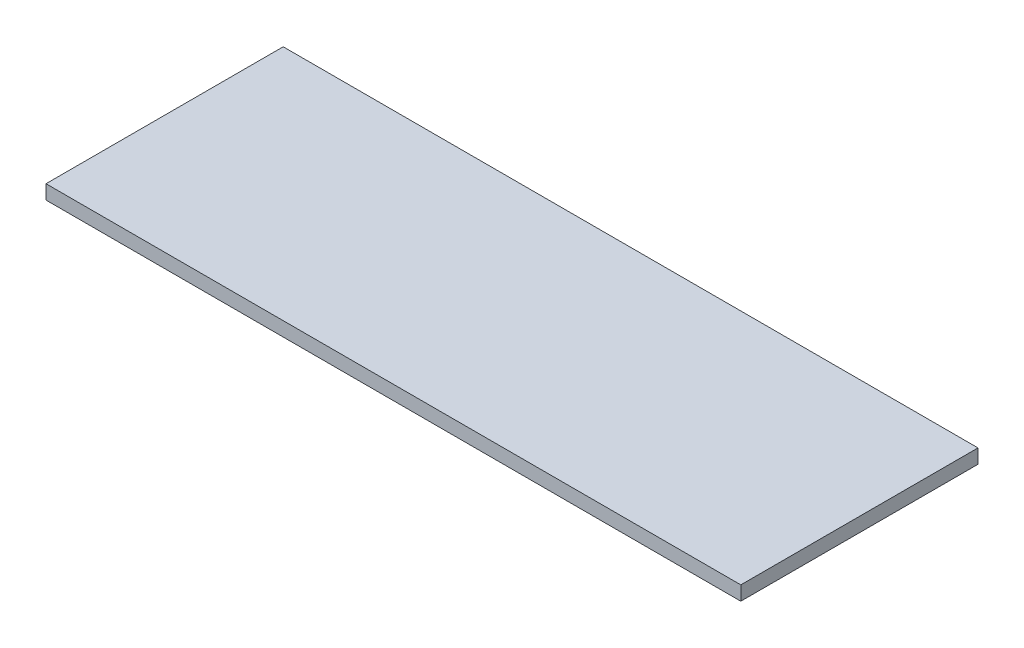
from build123d import *

# Parameters (mm, degrees)
SKETCH1_W           = 1860
SKETCH1_H           = 635
BOSS_EXTRUDE1_DEPTH = 38


with BuildPart() as part:
    # Sketch1 → Boss-Extrude1 (new body)
    with BuildSketch(Plane(origin=(0, 0, 0), x_dir=(1, 0, 0), z_dir=(0, 1, 0))):
        Rectangle(SKETCH1_W, SKETCH1_H)
    extrude(amount=BOSS_EXTRUDE1_DEPTH)


solid = part.part
